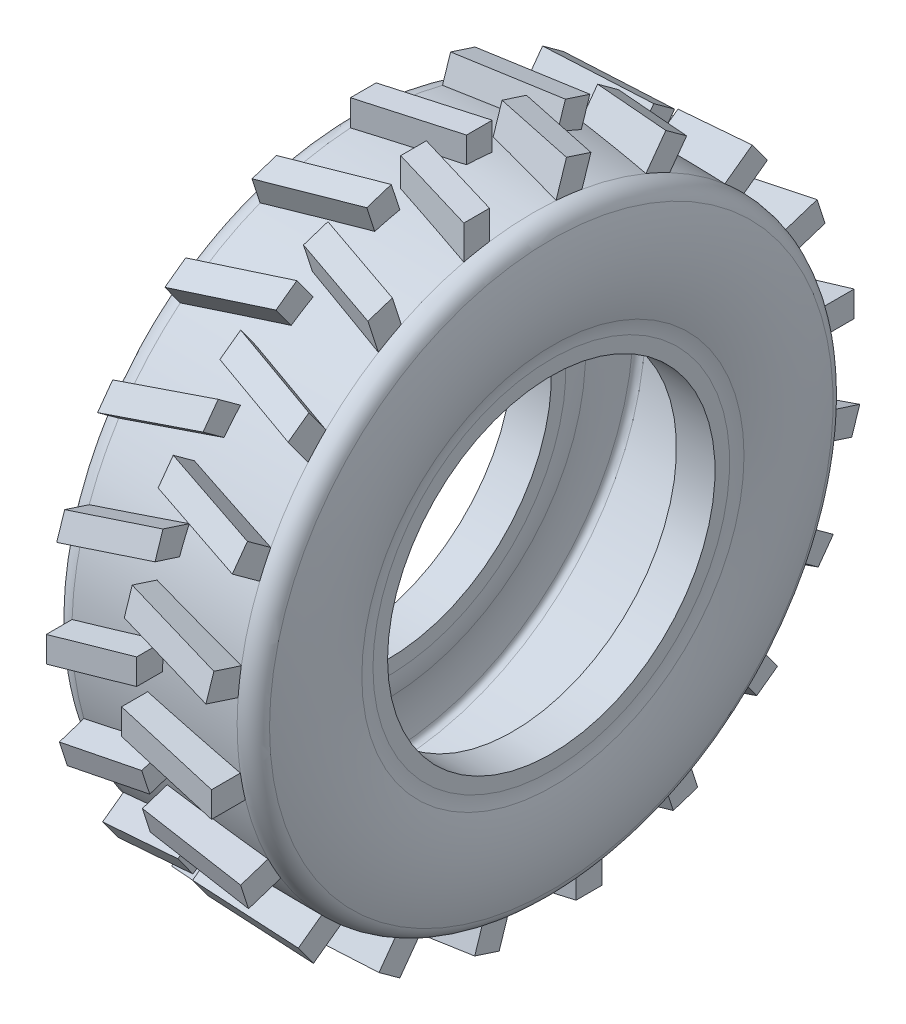
from build123d import *

# Parameters (mm, degrees)
BOSS_EXTRUDE1_START = -5.266359
BOSS_EXTRUDE1_DEPTH = 5.266359
CIRPATTERN1_COUNT   = 20


with BuildPart() as part:
    # Sketch1 → Revolve1 (revolve)
    with BuildSketch(Plane.XY):
        with BuildLine():
            Line((0, 46.004711313), (12.857304243, 46.004711313))
            ThreePointArc((12.857304243, 46.004711313), (14.654320443, 45.406946267), (15.735207663, 43.851866497))
            ThreePointArc((15.735207663, 43.851866497), (16.812860544, 36.813315162), (15.983231812, 29.741239314))
            ThreePointArc((15.983231812, 29.741239314), (15.795274895, 28.755136778), (15.732292019, 27.753258955))
            Line((15.732292019, 27.753258955), (15.732292019, 25.48075657))
            Line((15.732292019, 25.48075657), (9.732292019, 25.48075657))
            Line((9.732292019, 25.48075657), (9.732292019, 27.753258955))
            ThreePointArc((9.732292019, 27.753258955), (9.842512052, 29.506545145), (10.171436657, 31.232224584))
            ThreePointArc((10.171436657, 31.232224584), (10.782996907, 35.164262387), (10.626378026, 39.140491473))
            ThreePointArc((10.626378026, 39.140491473), (10.292989718, 39.758296132), (9.635639035, 40.004711313))
            Line((9.635639035, 40.004711313), (2.292850239, 40.004711313))
            Line((2.292850239, 40.004711313), (0, 40.004711313))
            Line((0, 40.004711313), (-9.635639035, 40.004711313))
            ThreePointArc((-9.635639035, 40.004711313), (-10.292989718, 39.758296132), (-10.626378026, 39.140491473))
            ThreePointArc((-10.626378026, 39.140491473), (-10.782996907, 35.164262387), (-10.171436657, 31.232224584))
            ThreePointArc((-10.171436657, 31.232224584), (-9.842512052, 29.506545145), (-9.732292019, 27.753258955))
            Line((-9.732292019, 27.753258955), (-9.732292019, 25.48075657))
            Line((-9.732292019, 25.48075657), (-15.732292019, 25.48075657))
            Line((-15.732292019, 25.48075657), (-15.732292019, 27.753258955))
            ThreePointArc((-15.732292019, 27.753258955), (-15.795274895, 28.755136778), (-15.983231812, 29.741239314))
            ThreePointArc((-15.983231812, 29.741239314), (-16.812860544, 36.813315162), (-15.735207663, 43.851866497))
            ThreePointArc((-15.735207663, 43.851866497), (-14.654320443, 45.406946267), (-12.857304243, 46.004711313))
            Line((-12.857304243, 46.004711313), (0, 46.004711313))
        make_face()
    revolve(axis=Axis((-86.851882295, 0, 0), (1, 0, 0)))

    # Sketch2 → Boss-Extrude1 (add)
    with BuildSketch(Plane(origin=(0, 50, 0), x_dir=(1, 0, 0), z_dir=(0, 1, 0)).offset(BOSS_EXTRUDE1_START)):
        Polygon((-1.142073443, -2.56209999), (-1.142073443, -6.56209999), (12.857304243, -10.739403893), (12.857304243, -6.739403893), align=None)
        Polygon((1.207660002, 1.335615201), (1.207660002, 5.335615201), (-12.857304243, 1.335615201), (-12.857304243, -2.664384799), align=None)
    boss_extrude1 = extrude(amount=BOSS_EXTRUDE1_DEPTH)

    # CirPattern1: Boss-Extrude1 ×20 about axis
    cirpattern1_axis = Axis((0, 0, 0), (1, 0, 0))
    for i in range(1, CIRPATTERN1_COUNT):
        add(boss_extrude1.rotate(cirpattern1_axis, i * 360 / CIRPATTERN1_COUNT))


solid = part.part
